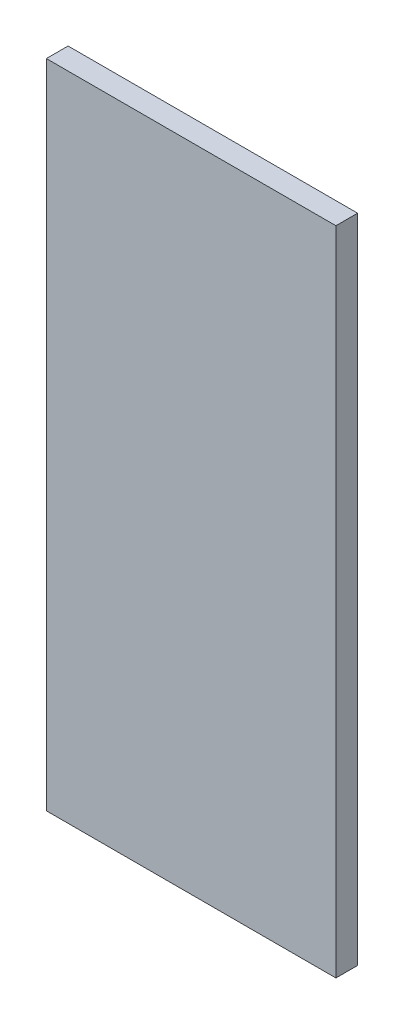
from build123d import *

# Parameters (mm, degrees)
ESQUISSE1_W        = 40
ESQUISSE1_H        = 90
BOSS_EXTRU_1_DEPTH = 3


with BuildPart() as part:
    # Esquisse1 → Boss.-Extru.1 (new body)
    with BuildSketch(Plane.XY):
        with Locations((20, -45)):
            Rectangle(ESQUISSE1_W, ESQUISSE1_H)
    extrude(amount=BOSS_EXTRU_1_DEPTH)


solid = part.part
